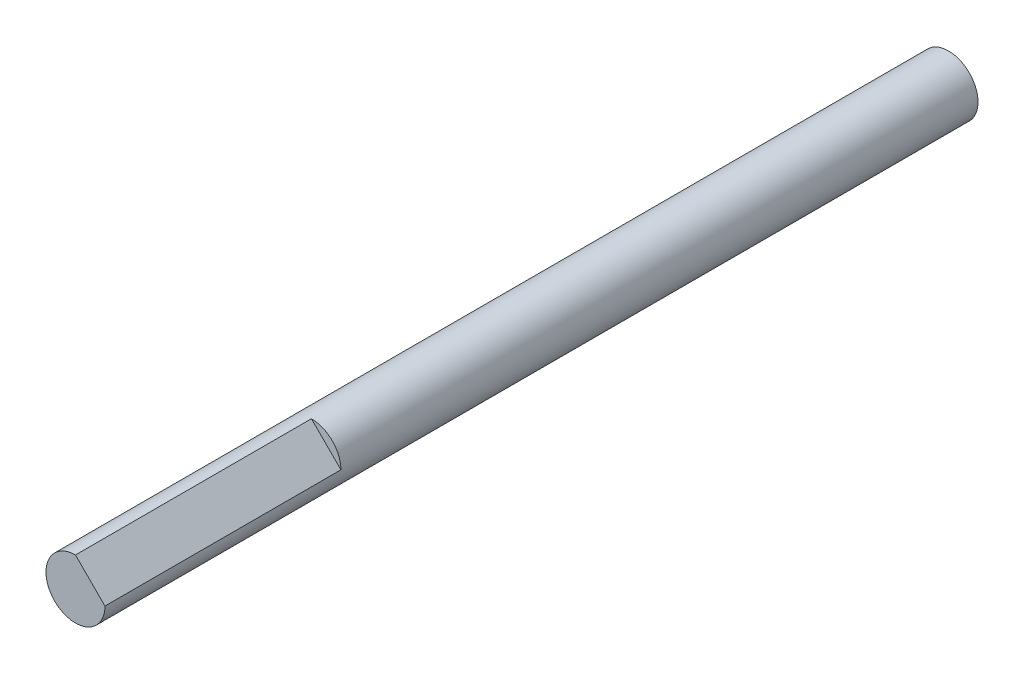
from build123d import *

# Parameters (mm, degrees)
SKETCH1_W                = 42.3
SKETCH1_H                = 42.3
BOSS_EXTRUDE1_DEPTH      = 50
SKETCH2_R                = 11
BOSS_EXTRUDE2_DEPTH      = 2
SKETCH3_R                = 1.75
CUT_EXTRUDE1_DEPTH       = 51
CUT_EXTRUDE2_DEPTH       = 51
SKETCH5_R                = 2.5
CUT_EXTRUDE3_DEPTH       = 53
SKETCH6_R                = 2.5
BOSS_EXTRUDE3_DEPTH      = 22
BOSS_EXTRUDE3_DEPTH_BACK = 52
SKETCH7_R                = 5
SKETCH7_R_2              = 2.5
CUT_EXTRUDE4_DEPTH       = 5
CUT_EXTRUDE5_DEPTH       = 20
SKETCH9_OUTSIDE_W        = 63.332
SKETCH9_OUTSIDE_H        = 63.332
SKETCH9_OUTSIDE_R        = 2.5
CUT_EXTRUDE6_DEPTH       = 75


with BuildPart() as part:
    # Sketch1 → Boss-Extrude1 (new body)
    with BuildSketch(Plane.XY):
        Rectangle(SKETCH1_W, SKETCH1_H)
    extrude(amount=BOSS_EXTRUDE1_DEPTH)

    # Sketch2 → Boss-Extrude2 (add)
    with BuildSketch(Plane.XY.offset(50)):
        Circle(SKETCH2_R)
    extrude(amount=BOSS_EXTRUDE2_DEPTH)

    # Sketch3 → Cut-Extrude1 (cut, through all)
    with BuildSketch(Plane.XY.offset(50)):
        with Locations((-16.55, 16.55)):
            Circle(SKETCH3_R)
        with Locations((16.55, 16.55)):
            Circle(SKETCH3_R)
        with Locations((16.55, -16.55)):
            Circle(SKETCH3_R)
        with Locations((-16.55, -16.55)):
            Circle(SKETCH3_R)
    extrude(amount=-CUT_EXTRUDE1_DEPTH, mode=Mode.SUBTRACT)

    # Sketch4 → Cut-Extrude2 (cut, through all)
    with BuildSketch(Plane.XY.offset(50)):
        Polygon((-21.15, 17.897308807), (-21.15, 21.15), (-17.897308807, 21.15), align=None)
        Polygon((17.897308807, 21.15), (21.15, 21.15), (21.15, 17.897308807), align=None)
        Polygon((21.15, -17.897308807), (21.15, -21.15), (17.897308807, -21.15), align=None)
        Polygon((-17.897308807, -21.15), (-21.15, -21.15), (-21.15, -17.897308807), align=None)
    extrude(amount=-CUT_EXTRUDE2_DEPTH, mode=Mode.SUBTRACT)

    # Sketch5 → Cut-Extrude3 (cut, through all)
    with BuildSketch(Plane.XY.offset(52)):
        Circle(SKETCH5_R)
    extrude(amount=-CUT_EXTRUDE3_DEPTH, mode=Mode.SUBTRACT)

    # Sketch6 → Boss-Extrude3 (add, two sides)
    with BuildSketch(Plane.XY.offset(52)) as boss_extrude3_sk:
        Circle(SKETCH6_R)
    extrude(amount=BOSS_EXTRUDE3_DEPTH)
    extrude(boss_extrude3_sk.sketch, amount=-BOSS_EXTRUDE3_DEPTH_BACK)

    # Sketch7 → Cut-Extrude4 (cut)
    with BuildSketch(Plane(origin=(0, 0, 0), x_dir=(-1, 0, 0), z_dir=(0, 0, -1))):
        Circle(SKETCH7_R)
        Circle(SKETCH7_R_2, mode=Mode.SUBTRACT)
    extrude(amount=-CUT_EXTRUDE4_DEPTH, mode=Mode.SUBTRACT)

    # Sketch8 → Cut-Extrude5 (cut)
    with BuildSketch(Plane.XY.offset(74)):
        with BuildLine():
            Line((2.5, 0), (0, 2.5))
            ThreePointArc((0, 2.5), (1.767766953, 1.767766953), (2.5, 0))
        make_face()
    extrude(amount=-CUT_EXTRUDE5_DEPTH, mode=Mode.SUBTRACT)

    # Sketch9 outside → Cut-Extrude6 (cut, through all)
    with BuildSketch(Plane.XY.offset(74)):
        Rectangle(SKETCH9_OUTSIDE_W, SKETCH9_OUTSIDE_H)
        Circle(SKETCH9_OUTSIDE_R, mode=Mode.SUBTRACT)
    extrude(amount=-CUT_EXTRUDE6_DEPTH, mode=Mode.SUBTRACT)


solid = part.part
